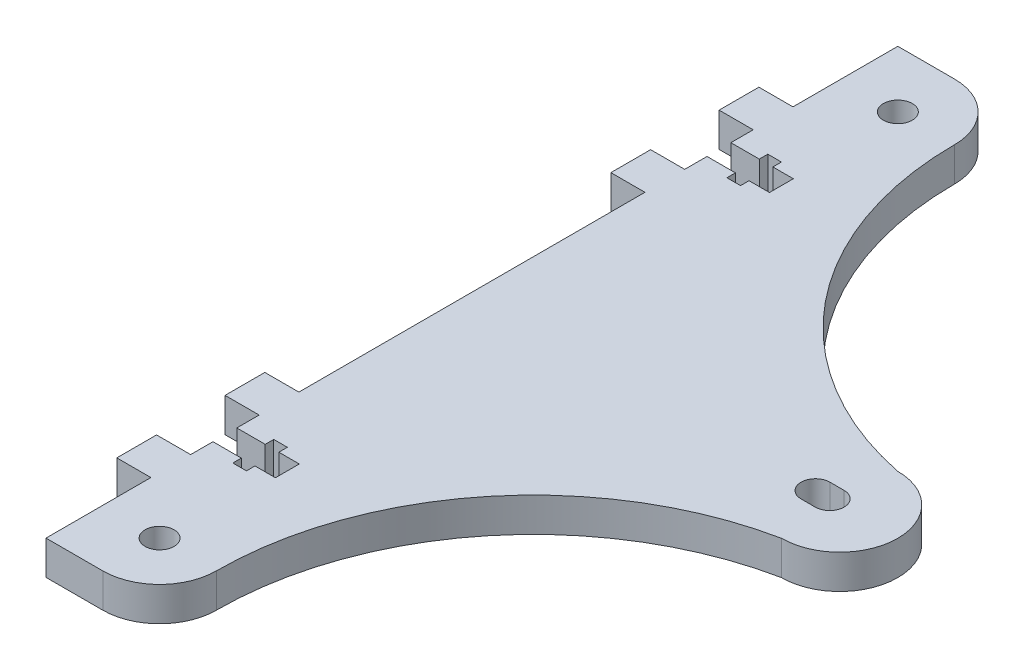
from build123d import *

# Parameters (mm, degrees)
EXTRUDE_1_DEPTH      = 6
SKETCH_2_R           = 2.55
CUT_EXTRUDE_1_DEPTH  = 7
SKETCH_21_W          = 7
SKETCH_21_H          = 6
EXTRUDE_2_DEPTH      = 6
CUT_EXTRUDE_11_DEPTH = 7
SKETCH_22_W          = 7
SKETCH_22_H          = 6
EXTRUDE_21_DEPTH     = 6
SKETCH_24_W          = 7
SKETCH_24_H          = 6
EXTRUDE_23_DEPTH     = 6
CUT_EXTRUDE_14_DEPTH = 7
SKETCH_25_W          = 7
SKETCH_25_H          = 6
EXTRUDE_24_DEPTH     = 6
SKETCH_26_W          = 7
SKETCH_26_H          = 6
EXTRUDE_25_DEPTH     = 6
SKETCH_27_W          = 7
SKETCH_27_H          = 6
EXTRUDE_26_DEPTH     = 6
SKETCH_28_W          = 7
SKETCH_28_H          = 6
EXTRUDE_27_DEPTH     = 6
SKETCH_29_W          = 7
SKETCH_29_H          = 6
EXTRUDE_28_DEPTH     = 6


with BuildPart() as part:
    # Эскиз1 → Бобышка-Вытянуть1 (new body)
    with BuildSketch(Plane(origin=(0, 0, 0), x_dir=(1, 0, 0), z_dir=(0, 1, 0))):
        with BuildLine():
            Line((-35, -65), (-35, -75))
            Line((-35, -75), (-25, -75))
            ThreePointArc((-25, -75), (-17.928932188, -72.071067812), (-15, -65))
            ThreePointArc((-15, -65), (-2.368853025, -29.632779179), (29.809139443, -10.26881824))
            ThreePointArc((29.809139443, -10.26881824), (40.031565804, -0.046391879), (29.809139443, 10.176034483))
            ThreePointArc((29.809139443, 10.176034483), (-2.372594749, 29.596870998), (-15, 65))
            ThreePointArc((-15, 65), (-17.928932188, 72.071067812), (-25, 75))
            Line((-25, 75), (-35, 75))
            Line((-35, 75), (-35, 65))
            Line((-35, 65), (-35, -65))
        make_face()
    extrude(amount=EXTRUDE_1_DEPTH)

    # Эскиз2 → Вырез-Вытянуть1 (cut, through all)
    with BuildSketch(Plane.XZ):
        with Locations((-25, -65)):
            Circle(SKETCH_2_R)
        with Locations((-25, 65)):
            Circle(SKETCH_2_R)
        with BuildLine():
            Line((28, -2.55), (25.5, -2.55))
            ThreePointArc((25.5, -2.55), (22.95, 0), (25.5, 2.55))
            Line((25.5, 2.55), (28, 2.55))
            ThreePointArc((28, 2.55), (30.55, 0), (28, -2.55))
        make_face()
    extrude(amount=-CUT_EXTRUDE_1_DEPTH, mode=Mode.SUBTRACT)

    # Эскиз21 → Бобышка-Вытянуть2 (add)
    with BuildSketch(Plane(origin=(15, 6, -43.5), x_dir=(0, 0, -1), z_dir=(0, 1, 0))):
        with Locations((-9.531849908, 53)):
            Rectangle(SKETCH_21_W, SKETCH_21_H)
        with Locations((9.531849908, 53)):
            Rectangle(SKETCH_21_W, SKETCH_21_H)
    extrude(amount=-EXTRUDE_2_DEPTH)

    # Эскиз31 → Вырез-Вытянуть11 (cut, through all)
    with BuildSketch(Plane(origin=(15, 6, -43.5), x_dir=(0, 0, -1), z_dir=(0, 1, 0))):
        Polygon((-2.1, 45), (-3.6, 45), (-3.6, 42.6), (-2.1, 42.6), (-2.1, 39), (2.1, 39), (2.1, 42.6), (3.6, 42.6), (3.6, 45), (2.1, 45), (2.1, 50), (-2.1, 50), align=None)
    extrude(amount=-CUT_EXTRUDE_11_DEPTH, mode=Mode.SUBTRACT)

    # Эскиз22 → Бобышка-Вытянуть21 (add)
    with BuildSketch(Plane(origin=(15, 0, -43.5), x_dir=(0, 0, 1), z_dir=(0, -1, 0))):
        with Locations((-9.531849908, 53)):
            Rectangle(SKETCH_22_W, SKETCH_22_H)
        with Locations((9.531849908, 53)):
            Rectangle(SKETCH_22_W, SKETCH_22_H)
    extrude(amount=-EXTRUDE_21_DEPTH)

    # Эскиз24 → Бобышка-Вытянуть23 (add)
    with BuildSketch(Plane(origin=(15, 0, 43.5), x_dir=(0, 0, 1), z_dir=(0, -1, 0))):
        with Locations((-9.531849908, 53)):
            Rectangle(SKETCH_24_W, SKETCH_24_H)
        with Locations((9.531849908, 53)):
            Rectangle(SKETCH_24_W, SKETCH_24_H)
    extrude(amount=-EXTRUDE_23_DEPTH)

    # Эскиз34 → Вырез-Вытянуть14 (cut, through all)
    with BuildSketch(Plane(origin=(15, 0, 43.5), x_dir=(0, 0, 1), z_dir=(0, -1, 0))):
        Polygon((-2.1, 45), (-3.6, 45), (-3.6, 42.6), (-2.1, 42.6), (-2.1, 39), (2.1, 39), (2.1, 42.6), (3.6, 42.6), (3.6, 45), (2.1, 45), (2.1, 50), (-2.1, 50), align=None)
    extrude(amount=-CUT_EXTRUDE_14_DEPTH, mode=Mode.SUBTRACT)

    # Эскиз25 → Бобышка-Вытянуть24 (add)
    with BuildSketch(Plane(origin=(15, 6, 43.5), x_dir=(0, 0, -1), z_dir=(0, 1, 0))):
        with Locations((-9.531849908, 53)):
            Rectangle(SKETCH_25_W, SKETCH_25_H)
        with Locations((9.531849908, 53)):
            Rectangle(SKETCH_25_W, SKETCH_25_H)
    extrude(amount=-EXTRUDE_24_DEPTH)

    # Эскиз26 → Бобышка-Вытянуть25 (add)
    with BuildSketch(Plane(origin=(15, 6, -43.5), x_dir=(0, 0, -1), z_dir=(0, 1, 0))):
        with Locations((-9.531849908, 53)):
            Rectangle(SKETCH_26_W, SKETCH_26_H)
        with Locations((9.531849908, 53)):
            Rectangle(SKETCH_26_W, SKETCH_26_H)
    extrude(amount=-EXTRUDE_25_DEPTH)

    # Эскиз27 → Бобышка-Вытянуть26 (add)
    with BuildSketch(Plane(origin=(15, 6, 43.5), x_dir=(0, 0, -1), z_dir=(0, 1, 0))):
        with Locations((-9.531849908, 53)):
            Rectangle(SKETCH_27_W, SKETCH_27_H)
        with Locations((9.531849908, 53)):
            Rectangle(SKETCH_27_W, SKETCH_27_H)
    extrude(amount=-EXTRUDE_26_DEPTH)

    # Эскиз28 → Бобышка-Вытянуть27 (add)
    with BuildSketch(Plane(origin=(15, 0, -43.5), x_dir=(0, 0, 1), z_dir=(0, -1, 0))):
        with Locations((-9.531849908, 53)):
            Rectangle(SKETCH_28_W, SKETCH_28_H)
        with Locations((9.531849908, 53)):
            Rectangle(SKETCH_28_W, SKETCH_28_H)
    extrude(amount=-EXTRUDE_27_DEPTH)

    # Эскиз29 → Бобышка-Вытянуть28 (add)
    with BuildSketch(Plane(origin=(15, 0, 43.5), x_dir=(0, 0, 1), z_dir=(0, -1, 0))):
        with Locations((-9.531849908, 53)):
            Rectangle(SKETCH_29_W, SKETCH_29_H)
        with Locations((9.531849908, 53)):
            Rectangle(SKETCH_29_W, SKETCH_29_H)
    extrude(amount=-EXTRUDE_28_DEPTH)


solid = part.part
